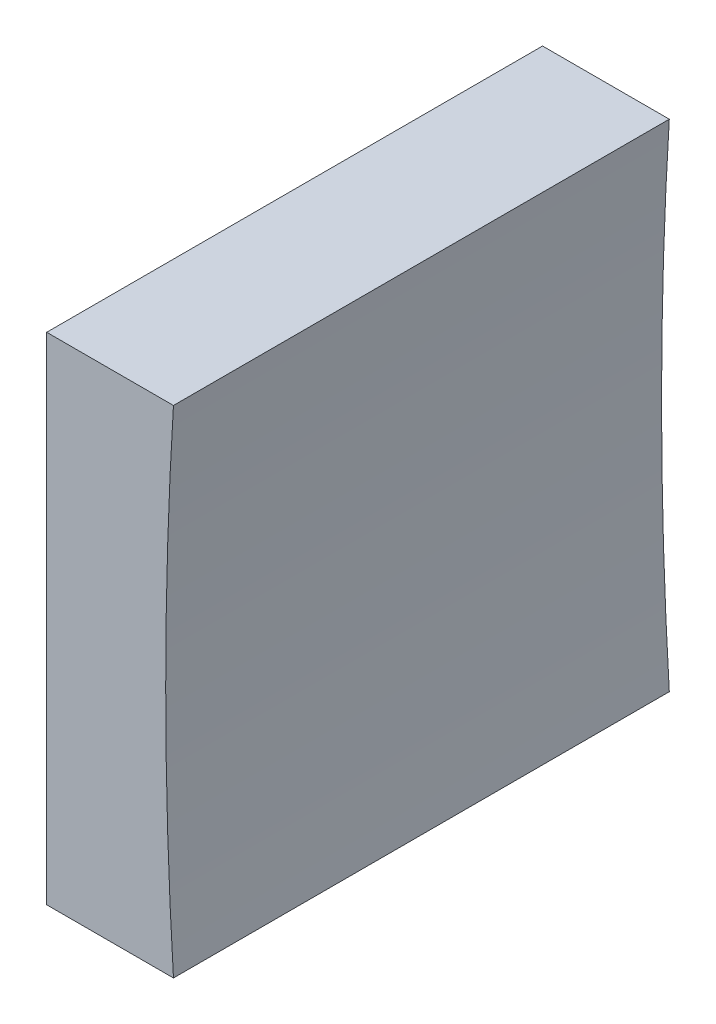
from build123d import *

# Parameters (mm, degrees)
EXTRUDE_1_DEPTH = 25


with BuildPart() as part:
    # 草图1 → 凸台-拉伸1 (new body)
    with BuildSketch(Plane.XY):
        with BuildLine():
            Line((284.707135631, 66.857929268), (284.707135631, 79.357929268))
            Line((284.707135631, 79.357929268), (291.098142848, 79.357929268))
            ThreePointArc((291.098142848, 79.357929268), (290.707135631, 66.857929268), (291.098142848, 54.357929268))
            Line((291.098142848, 54.357929268), (284.707135631, 54.357929268))
            Line((284.707135631, 54.357929268), (284.707135631, 66.857929268))
        make_face()
    extrude(amount=EXTRUDE_1_DEPTH)


solid = part.part
